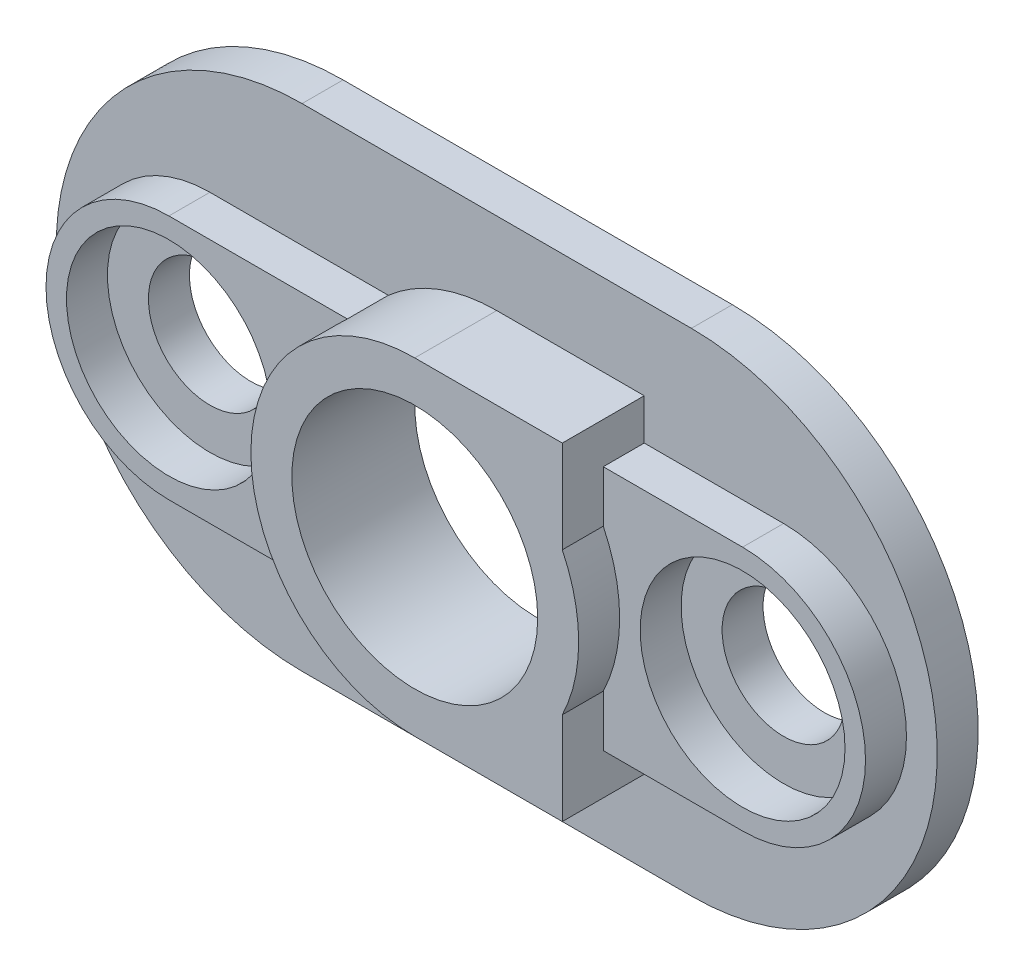
from build123d import *

# Parameters (mm, degrees)
EXTRUSION1_DEPTH        = 2
EXTRUSION4_DEPTH        = 2
EXTRUSION5_DEPTH        = 4
ESQUISSE3_R             = 6
ENL_V_MAT_EXTRU_1_DEPTH = 5
ESQUISSE5_R             = 3
ENL_V_MAT_EXTRU_2_DEPTH = 5
ESQUISSE6_R             = 5
ENL_V_MAT_EXTRU_3_DEPTH = 2


with BuildPart() as part:
    # Esquisse1 → Extrusion1 (new body)
    with BuildSketch(Plane.XY):
        with BuildLine():
            Line((-57.049073, 33.907042), (-38.049073, 33.907042))
            ThreePointArc((-38.049073, 33.907042), (-26.049073, 21.907042), (-38.049073, 9.907042))
            Line((-38.049073, 9.907042), (-57.049073, 9.907042))
            ThreePointArc((-57.049073, 9.907042), (-69.049073, 21.907042), (-57.049073, 33.907042))
        make_face()
    extrude(amount=EXTRUSION1_DEPTH)

    # Esquisse2 → Extrusion4 (add)
    with BuildSketch(Plane.XY.offset(2)):
        with BuildLine():
            Line((-61.549073, 27.907042), (-33.549073, 27.907042))
            ThreePointArc((-33.549073, 27.907042), (-27.549073, 21.907042), (-33.549073, 15.907042))
            Line((-33.549073, 15.907042), (-61.549073, 15.907042))
            ThreePointArc((-61.549073, 15.907042), (-67.549073, 21.907042), (-61.549073, 27.907042))
        make_face()
    extrude(amount=EXTRUSION4_DEPTH)

    # Esquisse4 → Extrusion5 (add)
    with BuildSketch(Plane.XY.offset(2)):
        with BuildLine():
            Line((-47.549305, 29.907042), (-40.349305, 29.907042))
            Line((-40.349305, 29.907042), (-40.349305, 25.394161155))
            ThreePointArc((-40.349305, 25.394161155), (-39.549305, 21.907042), (-40.349305, 18.419922845))
            Line((-40.349305, 18.419922845), (-40.349305, 13.907042))
            Line((-40.349305, 13.907042), (-47.549305, 13.907042))
            ThreePointArc((-47.549305, 13.907042), (-55.549305, 21.907042), (-47.549305, 29.907042))
        make_face()
    extrude(amount=EXTRUSION5_DEPTH)

    # Esquisse3 → Enlèv. mat.-Extru.1 (cut, symmetric)
    with BuildSketch(Plane.XY.offset(4)):
        with Locations((-47.549073, 21.907042)):
            Circle(ESQUISSE3_R)
    extrude(amount=ENL_V_MAT_EXTRU_1_DEPTH, both=True, mode=Mode.SUBTRACT)

    # Esquisse5 → Enlèv. mat.-Extru.2 (cut, through all)
    with BuildSketch(Plane.XY.offset(4)):
        with Locations((-61.549073, 21.907042)):
            Circle(ESQUISSE5_R)
        with Locations((-33.549073, 21.907042)):
            Circle(ESQUISSE5_R)
    extrude(amount=-ENL_V_MAT_EXTRU_2_DEPTH, mode=Mode.SUBTRACT)

    # Esquisse6 → Enlèv. mat.-Extru.3 (cut)
    with BuildSketch(Plane.XY.offset(4)):
        with Locations((-61.549073, 21.907042)):
            Circle(ESQUISSE6_R)
        with Locations((-33.549073, 21.907042)):
            Circle(ESQUISSE6_R)
    extrude(amount=-ENL_V_MAT_EXTRU_3_DEPTH, mode=Mode.SUBTRACT)


solid = part.part
